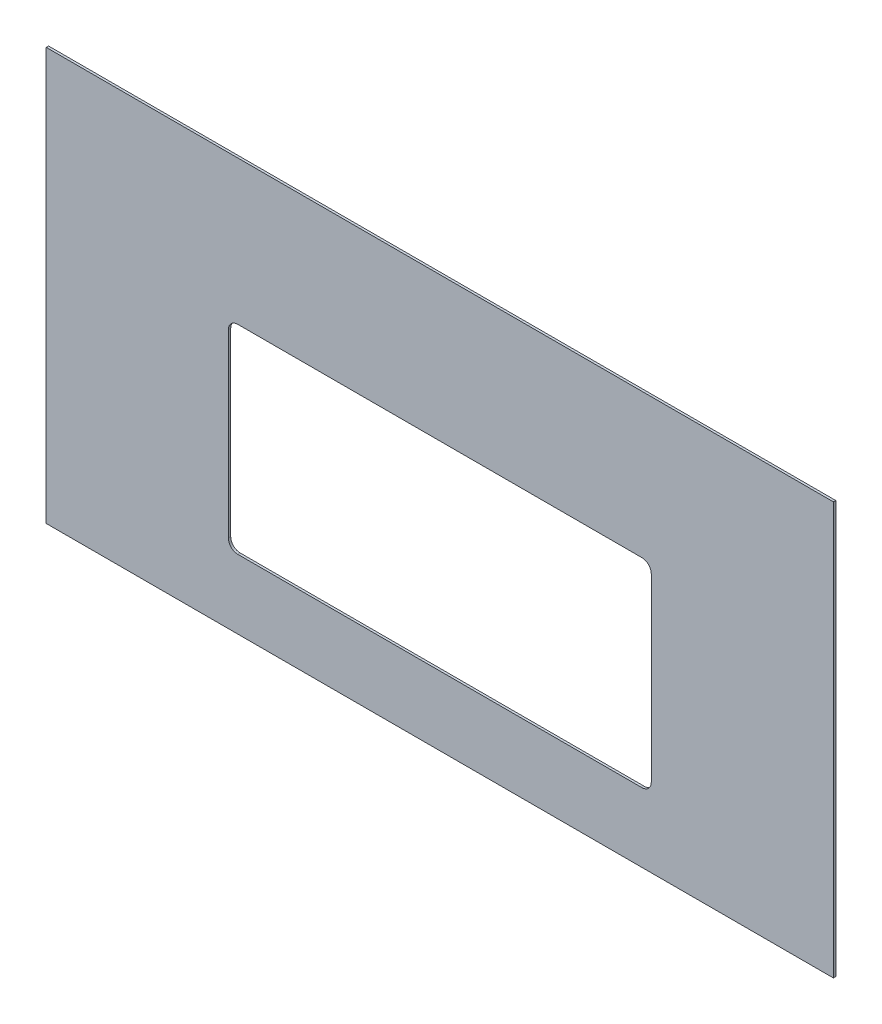
from build123d import *

# Parameters (mm, degrees)
SKETCH1_W           = 1066.8
SKETCH1_H           = 558.8
BOSS_EXTRUDE1_DEPTH = 3.175
CUT_EXTRUDE1_REACH  = 5.175


with BuildPart() as part:
    # Sketch1 → Boss-Extrude1 (new body)
    with BuildSketch(Plane.XY):
        Rectangle(SKETCH1_W, SKETCH1_H)
    extrude(amount=BOSS_EXTRUDE1_DEPTH)

    # Sketch2 → Cut-Extrude1 (cut, up to next)
    with BuildSketch(Plane.XY.offset(3.175), mode=Mode.PRIVATE) as cut_extrude1_sk1:
        with BuildLine():
            Line((-273.84375, 84.1375), (273.84375, 84.1375))
            ThreePointArc((273.84375, 84.1375), (282.824006121, 80.417756121), (286.54375, 71.4375))
            Line((286.54375, 71.4375), (286.54375, -173.0375))
            ThreePointArc((286.54375, -173.0375), (282.824006121, -182.017756121), (273.84375, -185.7375))
            Line((273.84375, -185.7375), (-273.84375, -185.7375))
            ThreePointArc((-273.84375, -185.7375), (-282.824006121, -182.017756121), (-286.54375, -173.0375))
            Line((-286.54375, -173.0375), (-286.54375, 71.4375))
            ThreePointArc((-286.54375, 71.4375), (-282.824006121, 80.417756121), (-273.84375, 84.1375))
        make_face()
    cut_extrude1_tool1 = extrude(cut_extrude1_sk1.sketch, amount=-CUT_EXTRUDE1_REACH, mode=Mode.PRIVATE) & part.part
    add(cut_extrude1_tool1.solids().sort_by_distance((0, -50.8, 3.175))[0], mode=Mode.SUBTRACT)


solid = part.part
